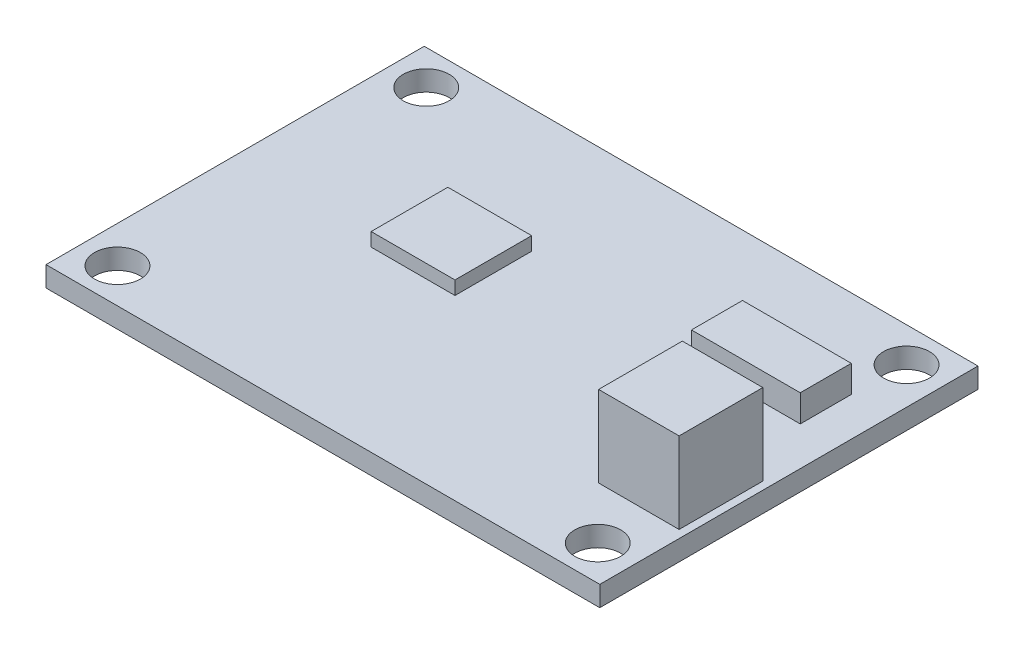
from build123d import *

# Parameters (mm, degrees)
SCHIZZO1_W                   = 41
SCHIZZO1_H                   = 28
ESTRUSIONE_ESTRUSIONE1_DEPTH = 1.5
FORO_PER_VITE_M3_1_D         = 3.4
SCHIZZO5_W                   = 6.206252214
SCHIZZO5_H                   = 5.678489494
ESTRUSIONE_ESTRUSIONE2_DEPTH = 1
SCHIZZO6_W                   = 5.958246431
SCHIZZO6_H                   = 6.198352004
ESTRUSIONE_ESTRUSIONE3_DEPTH = 6
SCHIZZO7_W                   = 8.055062412
SCHIZZO7_H                   = 3.777135449
ESTRUSIONE_ESTRUSIONE4_DEPTH = 2


with BuildPart() as part:
    # Schizzo1 → Estrusione-Estrusione1 (new body)
    with BuildSketch(Plane(origin=(0, 0, 0), x_dir=(1, 0, 0), z_dir=(0, 1, 0))):
        Rectangle(SCHIZZO1_W, SCHIZZO1_H)
    extrude(amount=ESTRUSIONE_ESTRUSIONE1_DEPTH)

    # Foro per Vite M3-1 (through all)
    with Locations(Plane(origin=(0, 1.5, 0), x_dir=(1, 0, 0), z_dir=(0, 1, 0))):
        with Locations((17.78, -11.43), (17.78, 11.43), (-17.78, 11.43), (-17.78, -11.43)):
            Hole(FORO_PER_VITE_M3_1_D / 2)

    # Schizzo5 → Estrusione-Estrusione2 (add)
    with BuildSketch(Plane(origin=(0, 1.5, 0), x_dir=(1, 0, 0), z_dir=(0, 1, 0))):
        with Locations((-6.482937483, 1.99695437)):
            Rectangle(SCHIZZO5_W, SCHIZZO5_H)
    extrude(amount=ESTRUSIONE_ESTRUSIONE2_DEPTH)

    # Schizzo6 → Estrusione-Estrusione3 (add)
    with BuildSketch(Plane(origin=(0, 1.5, 0), x_dir=(1, 0, 0), z_dir=(0, 1, 0))):
        with Locations((16.937357628, -4.446973273)):
            Rectangle(SCHIZZO6_W, SCHIZZO6_H)
    extrude(amount=ESTRUSIONE_ESTRUSIONE3_DEPTH)

    # Schizzo7 → Estrusione-Estrusione4 (add)
    with BuildSketch(Plane(origin=(0, 1.5, 0), x_dir=(1, 0, 0), z_dir=(0, 1, 0))):
        with Locations((13.608521834, 5.593352434)):
            Rectangle(SCHIZZO7_W, SCHIZZO7_H)
    extrude(amount=ESTRUSIONE_ESTRUSIONE4_DEPTH)


solid = part.part
